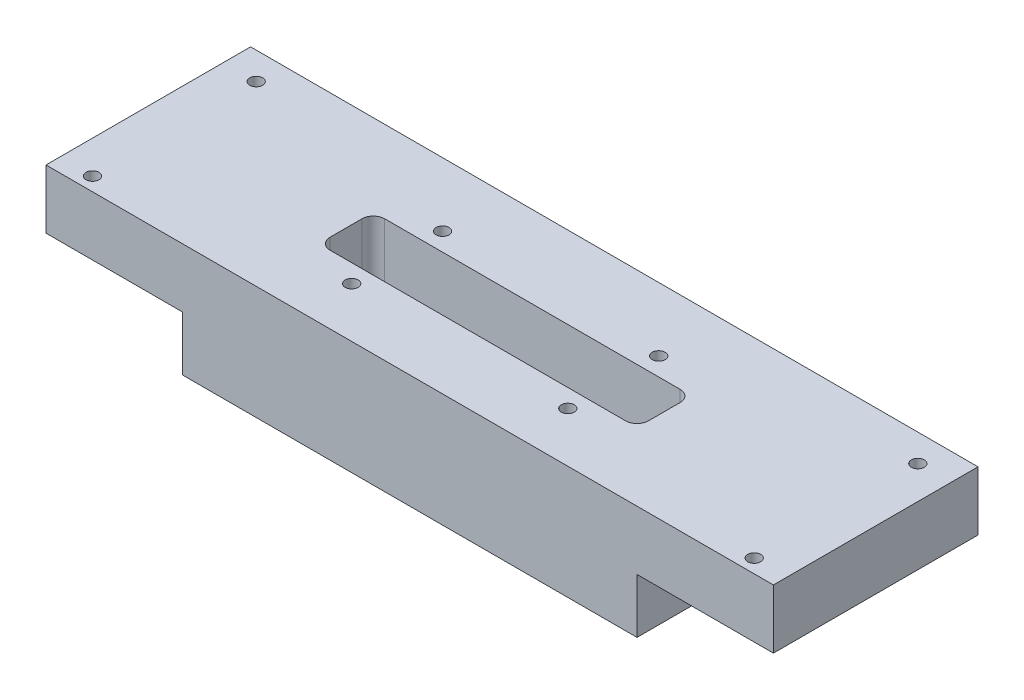
from build123d import *

# Parameters (mm, degrees)
SKETCH1_W                        = 160
SKETCH1_H                        = 45
EXTRUDE1_DEPTH                   = 13
SKETCH2_W                        = 100
SKETCH2_H                        = 45
EXTRUDE2_DEPTH                   = 12
SKETCH3_W                        = 70
SKETCH3_H                        = 12
EXTRUDE3_DEPTH                   = 26
FILLET1_R                        = 2.5
F_4_40_TAPPED_HOLE1_AT_2_COUNT   = 2
F_4_40_TAPPED_HOLE1_AT_2_PITCH   = 49.648766349
F_4_40_TAPPED_HOLE1_AT_3_COUNT   = 2
F_4_40_TAPPED_HOLE1_AT_3_PITCH   = 56.435804238
F_4_40_TAPPED_HOLE1_AT_4_COUNT   = 2
F_4_40_TAPPED_HOLE1_AT_4_PITCH   = 36
F_1_4_20_TAPPED_HOLE1_AT_2_COUNT = 2
F_1_4_20_TAPPED_HOLE1_AT_2_PITCH = 25
SKETCH7_R                        = 0.75
EXTRUDE4_DEPTH                   = 7


with BuildPart() as part:
    # Sketch1 → Extrude1 (new body)
    with BuildSketch(Plane(origin=(0, 0, 0), x_dir=(1, 0, 0), z_dir=(0, 1, 0))):
        Rectangle(SKETCH1_W, SKETCH1_H)
    extrude(amount=EXTRUDE1_DEPTH)

    # Sketch2 → Extrude2 (add)
    with BuildSketch(Plane.XZ):
        Rectangle(SKETCH2_W, SKETCH2_H)
    extrude(amount=EXTRUDE2_DEPTH)

    # Sketch3 → Extrude3 (cut, through all)
    with BuildSketch(Plane(origin=(0, 13, 0), x_dir=(1, 0, 0), z_dir=(0, 1, 0))):
        with Locations((0, -1.5)):
            Rectangle(SKETCH3_W, SKETCH3_H)
    extrude(amount=-EXTRUDE3_DEPTH, mode=Mode.SUBTRACT)

    # Fillet1
    fillet1_edges = [part.edges().sort_by_distance(p)[0] for p in [
        (-35, 0.5, 7.5),
        (-35, 0.5, -4.5),
        (35, 0.5, -4.5),
        (35, 0.5, 7.5),
    ]]
    fillet(fillet1_edges, radius=FILLET1_R)

    # Sketch5 → #4-40 Tapped Hole1 (revolve, cut)
    with BuildSketch(Plane(origin=(-72.77, 13, 19.5), x_dir=(0, 0, 1), z_dir=(1, 0, 0))):
        Polygon((0, 0), (0, 26.053752758), (1.1303, 25.3746), (1.1303, 5.6896), (1.4224, 5.6896), (1.4224, 0), align=None)
    f_4_40_tapped_hole1 = revolve(axis=Axis((-72.77, 19.35, 19.5), (0, -1, 0)), mode=Mode.SUBTRACT)

    # #4-40 Tapped Hole1 at 2: #4-40 Tapped Hole1 ×2
    with Locations(*[Vector(0.986932881, 0, -0.161131899) * (i * F_4_40_TAPPED_HOLE1_AT_2_PITCH) for i in range(1, F_4_40_TAPPED_HOLE1_AT_2_COUNT)]):
        add(f_4_40_tapped_hole1, mode=Mode.SUBTRACT)

    # #4-40 Tapped Hole1 at 3: #4-40 Tapped Hole1 ×2
    with Locations(*[Vector(0.868243142, 0, -0.496138938) * (i * F_4_40_TAPPED_HOLE1_AT_3_PITCH) for i in range(1, F_4_40_TAPPED_HOLE1_AT_3_COUNT)]):
        add(f_4_40_tapped_hole1, mode=Mode.SUBTRACT)

    # #4-40 Tapped Hole1 at 4: #4-40 Tapped Hole1 ×2
    with Locations(*[(0, 0, -i * F_4_40_TAPPED_HOLE1_AT_4_PITCH) for i in range(1, F_4_40_TAPPED_HOLE1_AT_4_COUNT)]):
        add(f_4_40_tapped_hole1, mode=Mode.SUBTRACT)

    # Mirror1: #4-40 Tapped Hole1 across plane
    add(f_4_40_tapped_hole1.mirror(Plane(origin=(0, 0, 0), x_dir=(0, 0, 1), z_dir=(1, 0, 0))), mode=Mode.SUBTRACT)

    # Mirror1 copy 1 sketch → Mirror1 copy 1 (revolve, cut)
    with BuildSketch(Plane(origin=(23.77, 13, 11.5), x_dir=(0, 0, 1), z_dir=(-1, 0, 0))):
        Polygon((0, 0), (0, -26.053752758), (1.1303, -25.3746), (1.1303, -5.6896), (1.4224, -5.6896), (1.4224, 0), align=None)
    revolve(axis=Axis((23.77, 19.35, 11.5), (0, 1, 0)), mode=Mode.SUBTRACT)

    # Mirror1 copy 2 sketch → Mirror1 copy 2 (revolve, cut)
    with BuildSketch(Plane(origin=(23.77, 13, -8.5), x_dir=(0, 0, 1), z_dir=(-1, 0, 0))):
        Polygon((0, 0), (0, -26.053752758), (1.1303, -25.3746), (1.1303, -5.6896), (1.4224, -5.6896), (1.4224, 0), align=None)
    revolve(axis=Axis((23.77, 19.35, -8.5), (0, 1, 0)), mode=Mode.SUBTRACT)

    # Mirror1 copy 3 sketch → Mirror1 copy 3 (revolve, cut)
    with BuildSketch(Plane(origin=(72.77, 13, -16.5), x_dir=(0, 0, 1), z_dir=(-1, 0, 0))):
        Polygon((0, 0), (0, -26.053752758), (1.1303, -25.3746), (1.1303, -5.6896), (1.4224, -5.6896), (1.4224, 0), align=None)
    revolve(axis=Axis((72.77, 19.35, -16.5), (0, 1, 0)), mode=Mode.SUBTRACT)

    # Sketch6 → 1/4-20 Tapped Hole1 (revolve, cut)
    with BuildSketch(Plane(origin=(50, -7, -14.5), x_dir=(0, 0, -1), z_dir=(0, 1, 0))):
        Polygon((0, 0), (0, 21.533827702), (2.5527, 20.0000108), (2.5527, 12.7), (3.175, 12.7), (3.175, 0), align=None)
    f_1_4_20_tapped_hole1 = revolve(axis=Axis((56.35, -7, -14.5), (-1, 0, 0)), mode=Mode.SUBTRACT)

    # 1/4-20 Tapped Hole1 at 2: 1/4-20 Tapped Hole1 ×2
    with Locations(*[(0, 0, i * F_1_4_20_TAPPED_HOLE1_AT_2_PITCH) for i in range(1, F_1_4_20_TAPPED_HOLE1_AT_2_COUNT)]):
        add(f_1_4_20_tapped_hole1, mode=Mode.SUBTRACT)

    # Sketch7 → Extrude4 (cut)
    with BuildSketch(Plane.XZ.offset(12)):
        with Locations(Location((31, -14.5, 0), (0, 0, 270))):  # turned: the seam where the file's is
            Circle(SKETCH7_R)
        with Locations(Location((31, 10.5, 0), (0, 0, 270))):  # turned: the seam where the file's is
            Circle(SKETCH7_R)
    extrude4 = extrude(amount=-EXTRUDE4_DEPTH, mode=Mode.SUBTRACT)

    # Mirror2: Extrude4, 1/4-20 Tapped Hole1 across plane
    add(extrude4.mirror(Plane(origin=(0, 0, 0), x_dir=(0, 0, 1), z_dir=(1, 0, 0))), mode=Mode.SUBTRACT)
    add(f_1_4_20_tapped_hole1.mirror(Plane(origin=(0, 0, 0), x_dir=(0, 0, 1), z_dir=(1, 0, 0))), mode=Mode.SUBTRACT)

    # Mirror2 copy 1 sketch → Mirror2 copy 1 (revolve, cut)
    with BuildSketch(Plane(origin=(-50, -7, 10.5), x_dir=(0, 0, -1), z_dir=(0, 1, 0))):
        Polygon((0, 0), (0, -21.533827702), (2.5527, -20.0000108), (2.5527, -12.7), (3.175, -12.7), (3.175, 0), align=None)
    revolve(axis=Axis((-56.35, -7, 10.5), (-1, 0, 0)), mode=Mode.SUBTRACT)

    # Sketch8 → #4-40 Tapped Hole2 (revolve, cut)
    with BuildSketch(Plane(origin=(15, -9, -22.5), x_dir=(0, 1, 0), z_dir=(1, 0, 0))):
        Polygon((0, 0), (0, 20.973752758), (1.1303, 20.2946), (1.1303, 8.2296), (1.4224, 8.2296), (1.4224, 0), align=None)
    f_4_40_tapped_hole2 = revolve(axis=Axis((15, -9, -28.85), (0, 0, 1)), mode=Mode.SUBTRACT)

    # Mirror3: #4-40 Tapped Hole2 across plane
    add(f_4_40_tapped_hole2.mirror(Plane(origin=(0, 0, 0), x_dir=(0, 0, 1), z_dir=(1, 0, 0))), mode=Mode.SUBTRACT)


solid = part.part
